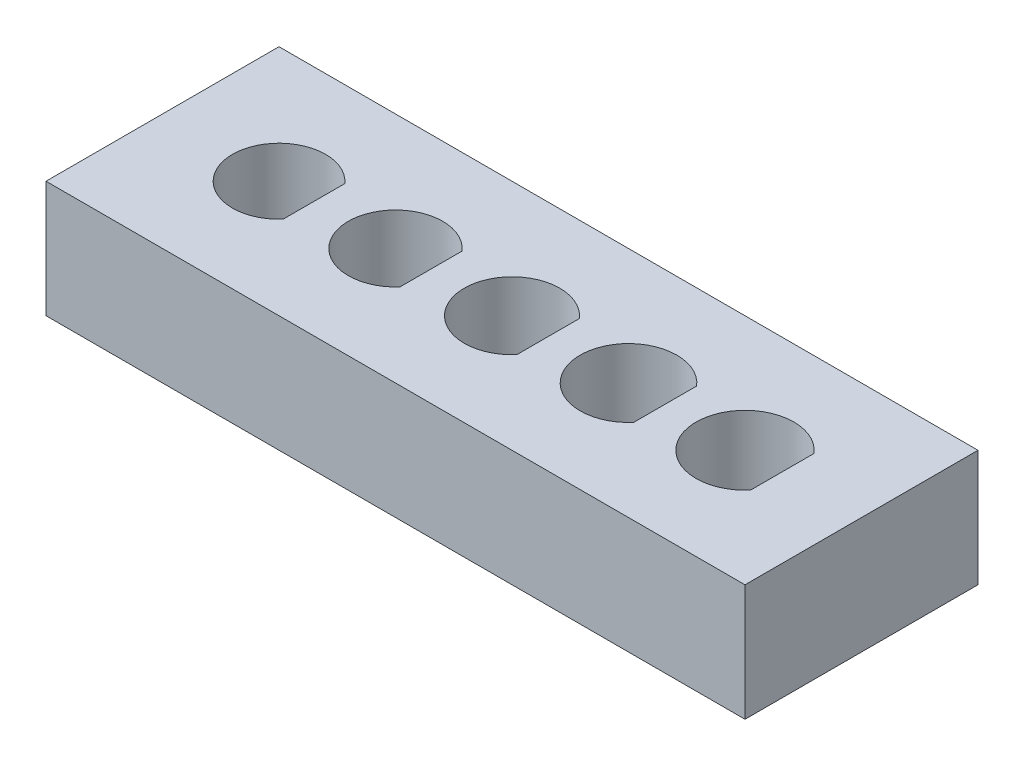
from build123d import *

# Parameters (mm, degrees)
SKETCH1_W           = 30
SKETCH1_H           = 10
BOSS_EXTRUDE1_DEPTH = 5


with BuildPart() as part:
    # Sketch1 → Boss-Extrude1 (new body)
    with BuildSketch(Plane(origin=(0, 0, 0), x_dir=(1, 0, 0), z_dir=(0, 1, 0))):
        Rectangle(SKETCH1_W, SKETCH1_H)
        with BuildLine():
            ThreePointArc((11.6, 1.360147051), (7.9, 0), (11.6, -1.360147051))
            Line((11.6, -1.360147051), (11.6, 1.360147051))
        make_face(mode=Mode.SUBTRACT)
        with BuildLine():
            ThreePointArc((6.575, 1.350925609), (2.925, 0), (6.575, -1.350925609))
            Line((6.575, -1.350925609), (6.575, 1.350925609))
        make_face(mode=Mode.SUBTRACT)
        with BuildLine():
            ThreePointArc((1.55, 1.341640786), (-2.05, 0), (1.55, -1.341640786))
            Line((1.55, -1.341640786), (1.55, 1.341640786))
        make_face(mode=Mode.SUBTRACT)
        with BuildLine():
            ThreePointArc((-3.475, 1.332291259), (-7.025, 0), (-3.475, -1.332291259))
            Line((-3.475, -1.332291259), (-3.475, 1.332291259))
        make_face(mode=Mode.SUBTRACT)
        with BuildLine():
            ThreePointArc((-8.5, 1.322875656), (-12, 0), (-8.5, -1.322875656))
            Line((-8.5, -1.322875656), (-8.5, 1.322875656))
        make_face(mode=Mode.SUBTRACT)
    extrude(amount=-BOSS_EXTRUDE1_DEPTH)


solid = part.part
